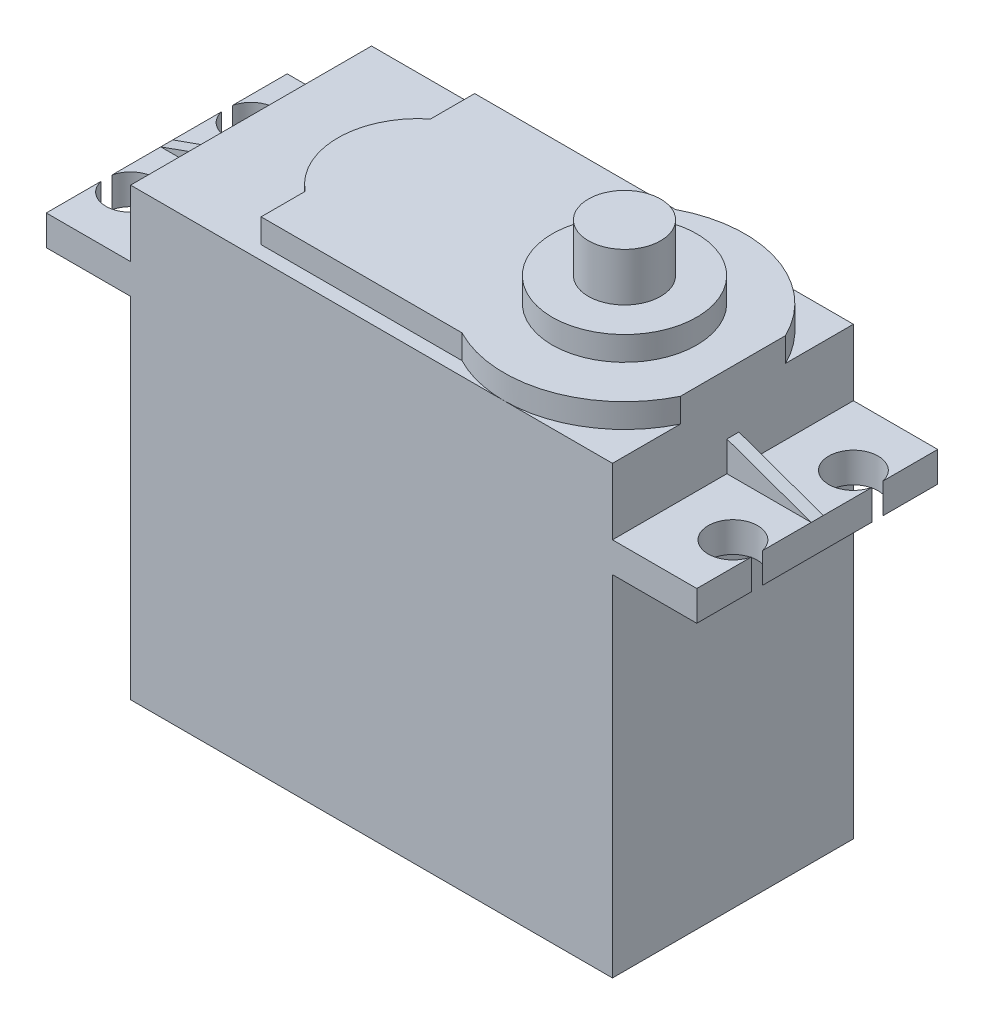
from build123d import *

# Parameters (mm, degrees)
SKETCH1_W                = 40
SKETCH1_H                = 20
BOSS_EXTRUDE1_DEPTH      = 29
SKETCH2_W                = 54
SKETCH2_H                = 20
BOSS_EXTRUDE2_DEPTH      = 2.5
SKETCH3_W                = 40
SKETCH3_H                = 20
BOSS_EXTRUDE3_DEPTH      = 5.5
BOSS_EXTRUDE4_DEPTH      = 2
SKETCH5_R                = 6
BOSS_EXTRUDE5_DEPTH      = 2
SKETCH6_R                = 3
BOSS_EXTRUDE6_DEPTH      = 4
SKETCH7_R                = 2.05
CUT_EXTRUDE2_DEPTH       = 4
BOSS_EXTRUDE8_DEPTH      = 0.5
BOSS_EXTRUDE8_DEPTH_BACK = 0.5


with BuildPart() as part:
    # Sketch1 → Boss-Extrude1 (new body)
    with BuildSketch(Plane(origin=(0, 0, 0), x_dir=(1, 0, 0), z_dir=(0, 1, 0))):
        Rectangle(SKETCH1_W, SKETCH1_H)
    extrude(amount=BOSS_EXTRUDE1_DEPTH)

    # Sketch2 → Boss-Extrude2 (add)
    with BuildSketch(Plane(origin=(0, 29, 0), x_dir=(1, 0, 0), z_dir=(0, 1, 0))):
        Rectangle(SKETCH2_W, SKETCH2_H)
    extrude(amount=BOSS_EXTRUDE2_DEPTH)

    # Sketch3 → Boss-Extrude3 (add)
    with BuildSketch(Plane(origin=(0, 31.5, 0), x_dir=(1, 0, 0), z_dir=(0, 1, 0))):
        Rectangle(SKETCH3_W, SKETCH3_H)
    extrude(amount=BOSS_EXTRUDE3_DEPTH)

    # Sketch4 → Boss-Extrude4 (add)
    with BuildSketch(Plane(origin=(0, 37, 0), x_dir=(1, 0, 0), z_dir=(0, 1, 0))):
        with BuildLine():
            Line((-10.302888497, 5.203858548), (-10.302888497, 8.863863335))
            Line((-10.302888497, 8.863863335), (6.370537096, 8.863863335))
            ThreePointArc((6.370537096, 8.863863335), (14.138323544, 9.494784112), (20, 4.358898944))
            Line((20, 4.358898944), (20, -4.358898944))
            ThreePointArc((20, -4.358898944), (14.138323544, -9.494784112), (6.370537096, -8.863863335))
            Line((6.370537096, -8.863863335), (-10.302888497, -8.863863335))
            Line((-10.302888497, -8.863863335), (-10.302888497, -5.203858548))
            ThreePointArc((-10.302888497, -5.203858548), (-12.798836729, 0), (-10.302888497, 5.203858548))
        make_face()
    extrude(amount=BOSS_EXTRUDE4_DEPTH)

    # Sketch5 → Boss-Extrude5 (add)
    with BuildSketch(Plane(origin=(0, 39, 0), x_dir=(1, 0, 0), z_dir=(0, 1, 0))):
        with Locations((11, 0)):
            Circle(SKETCH5_R)
    extrude(amount=BOSS_EXTRUDE5_DEPTH)

    # Sketch6 → Boss-Extrude6 (add)
    with BuildSketch(Plane(origin=(0, 41, 0), x_dir=(1, 0, 0), z_dir=(0, 1, 0))):
        with Locations((11, 0)):
            Circle(SKETCH6_R)
    extrude(amount=BOSS_EXTRUDE6_DEPTH)

    # Sketch7 → Cut-Extrude2 (cut)
    with BuildSketch(Plane(origin=(0, 31.5, 0), x_dir=(1, 0, 0), z_dir=(0, 1, 0))):
        with Locations((-25, 5)):
            Circle(SKETCH7_R)
        with Locations((-25, -5)):
            Circle(SKETCH7_R)
        with Locations((25, 5)):
            Circle(SKETCH7_R)
        with Locations((25, -5)):
            Circle(SKETCH7_R)
    extrude(amount=-CUT_EXTRUDE2_DEPTH, mode=Mode.SUBTRACT)

    # Sketch8 → Boss-Extrude8 (add, two sides)
    with BuildSketch(Plane.XY) as boss_extrude8_sk:
        Polygon((-20, 34), (-27, 31.5), (-20, 31.5), align=None)
        Polygon((20, 31.5), (20, 34), (27, 31.5), align=None)
    extrude(amount=BOSS_EXTRUDE8_DEPTH)
    extrude(boss_extrude8_sk.sketch, amount=-BOSS_EXTRUDE8_DEPTH_BACK)


solid = part.part
